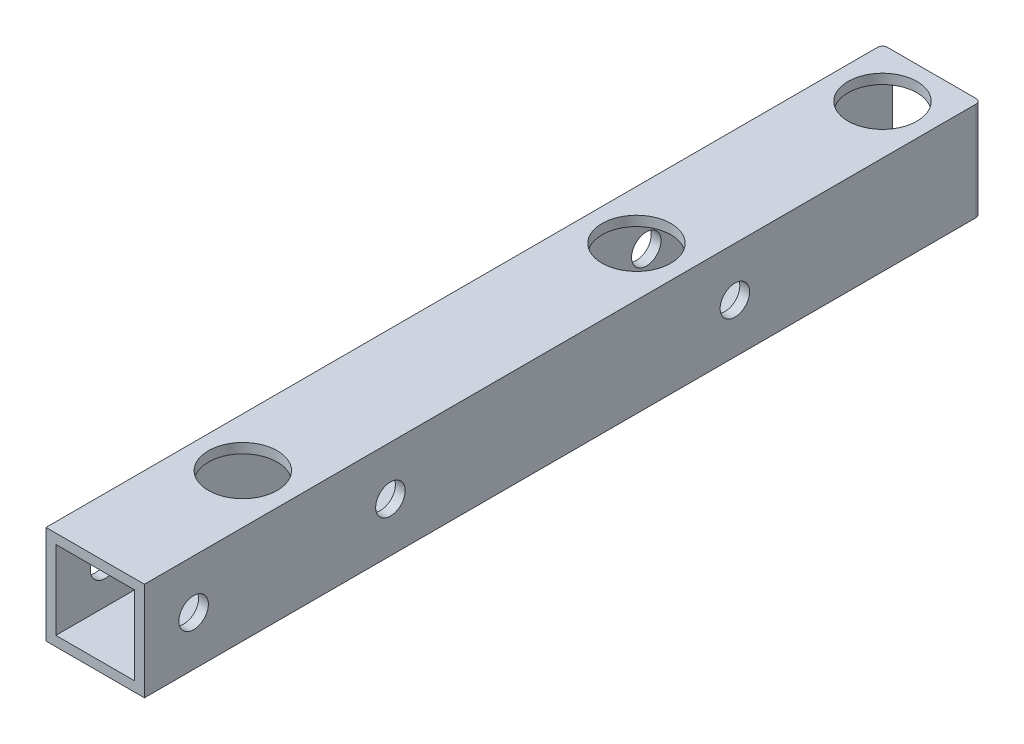
from build123d import *

# Parameters (mm, degrees)
SKETCH_1_W          = 10
SKETCH_1_H          = 10
SKETCH_1_W_2        = 8
SKETCH_1_H_2        = 8
EXTRUDE_1_DEPTH     = 85
SKETCH_2_R          = 1.5
CUT_EXTRUDE_1_DEPTH = 11
SKETCH_3_R          = 1.5
CUT_EXTRUDE_2_DEPTH = 10
SKETCH_4_R          = 3.5
CUT_EXTRUDE_3_DEPTH = 5
FILLET_1_R          = 0.5


with BuildPart() as part:
    # 草图1 → 拉伸-薄壁1 (new body)
    with BuildSketch(Plane.XY):
        Rectangle(SKETCH_1_W, SKETCH_1_H)
        Rectangle(SKETCH_1_W_2, SKETCH_1_H_2, mode=Mode.SUBTRACT)
    extrude(amount=EXTRUDE_1_DEPTH)

    # 草图2 → 切除-拉伸1 (cut, through all)
    with BuildSketch(Plane(origin=(0, 5, 0), x_dir=(1, 0, 0), z_dir=(0, 1, 0))):
        with Locations((0, -70)):
            Circle(SKETCH_2_R)
        with Locations((0, -5)):
            Circle(SKETCH_2_R)
        with Locations((0, -30)):
            Circle(SKETCH_2_R)
    extrude(amount=-CUT_EXTRUDE_1_DEPTH, mode=Mode.SUBTRACT)

    # 草图3 → 切除-拉伸2 (cut)
    with BuildSketch(Plane.ZY.offset(5)):
        with Locations((25, 0)):
            Circle(SKETCH_3_R)
        with Locations((60, 0)):
            Circle(SKETCH_3_R)
        with Locations((80, 0)):
            Circle(SKETCH_3_R)
    extrude(amount=-CUT_EXTRUDE_2_DEPTH, mode=Mode.SUBTRACT)

    # 草图4 → 切除-拉伸3 (cut)
    with BuildSketch(Plane(origin=(0, 5, 0), x_dir=(1, 0, 0), z_dir=(0, 1, 0))):
        with Locations((0, -5)):
            Circle(SKETCH_4_R)
        with Locations((0, -30)):
            Circle(SKETCH_4_R)
        with Locations((0, -70)):
            Circle(SKETCH_4_R)
    extrude(amount=-CUT_EXTRUDE_3_DEPTH, mode=Mode.SUBTRACT)

    # 圆角1
    fillet_1_edges = [part.edges().sort_by_distance(p)[0] for p in [
        (5, 0, 0),
        (-5, 0, 0),
    ]]
    fillet(fillet_1_edges, radius=FILLET_1_R)


solid = part.part
